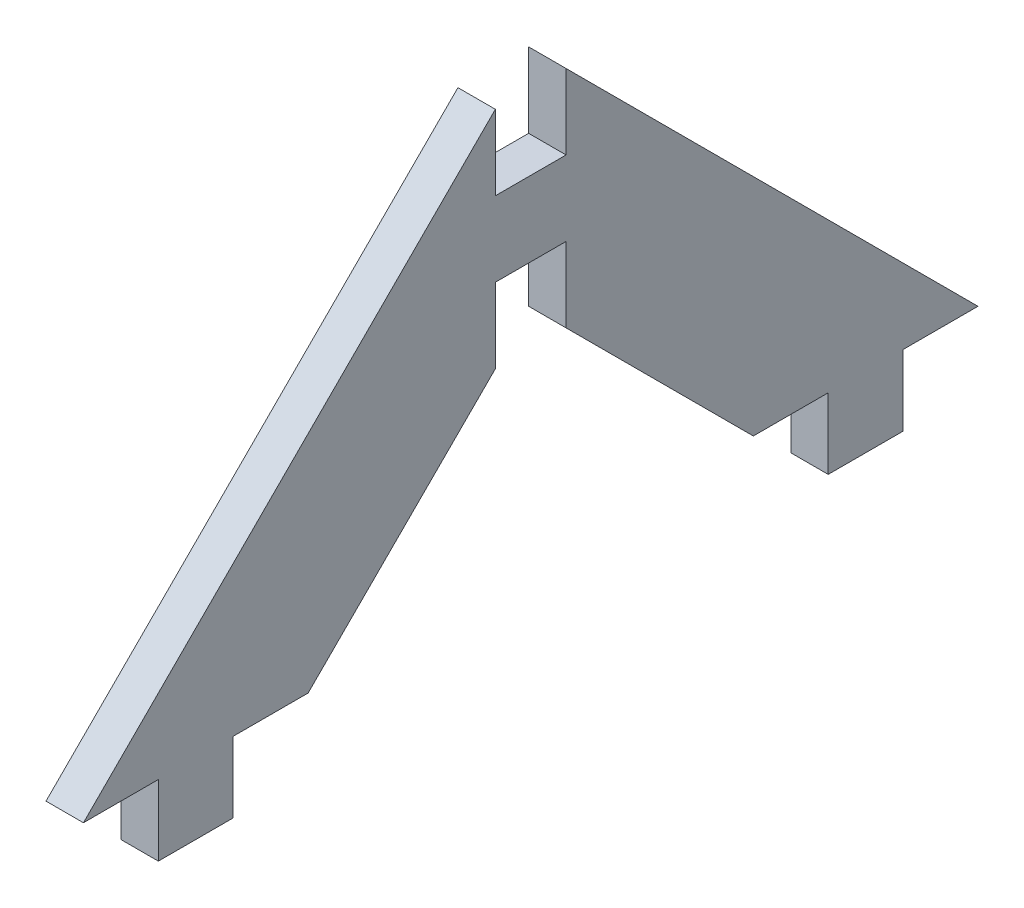
from build123d import *

# Parameters (mm, degrees)
BOSS_EXTRUDE1_DEPTH = 3.175


with BuildPart() as part:
    # Sketch1 → Boss-Extrude1 (new body)
    with BuildSketch(Plane(origin=(0, 0, 0), x_dir=(0, 0, -1), z_dir=(1, 0, 0))):
        Polygon((0, 0), (6.35, 0), (6.35, -5.9944), (12.7, -5.9944), (12.7, 0), (19.05, 0), (34.925, 15.875), (34.925, 22.225), (40.9194, 22.225), (40.9194, 15.875), (56.7944, 0), (63.1444, 0), (63.1444, -5.9944), (69.4944, -5.9944), (69.4944, 0), (75.8444, 0), (40.9194, 34.925), (40.9194, 28.575), (34.925, 28.575), (34.925, 34.925), align=None)
    extrude(amount=BOSS_EXTRUDE1_DEPTH)


solid = part.part
